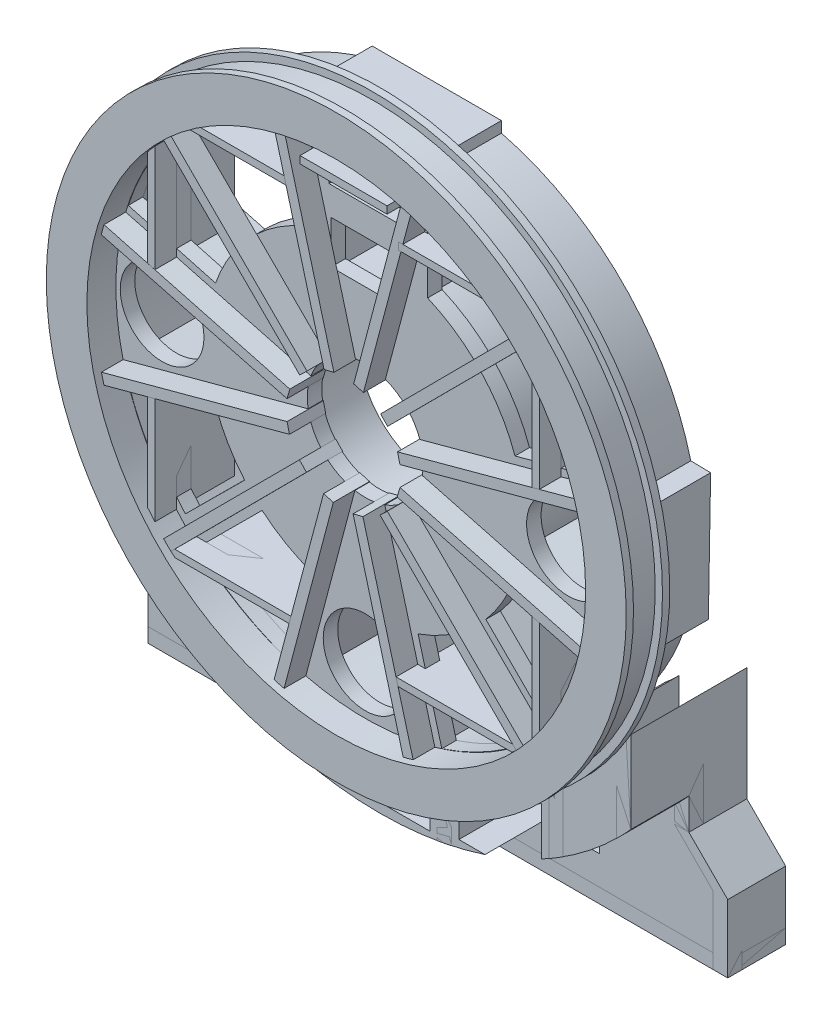
from build123d import *
from build123d.topology import SkipClean

# Parameters (mm, degrees)
SKETCH1_R                   = 200
BOSS_EXTRUDE1_DEPTH         = 5
SKETCH2_R                   = 195
BOSS_EXTRUDE2_DEPTH         = 10
SKETCH4_R                   = 180
SKETCH4_R_2                 = 172
BOSS_EXTRUDE3_DEPTH         = 40
CUT_EXTRUDE1_DEPTH          = 286.657137142
CUT_EXTRUDE1_DEPTH_BACK     = 286.657137142
SKETCH6_R                   = 40
SKETCH7_R                   = 172
CUT_EXTRUDE2_DEPTH          = 20
BOSS_EXTRUDE12_START        = -25
BOSS_EXTRUDE12_DEPTH        = 65
CIRPATTERN7_COUNT           = 12
SKETCH5_R                   = 104.5
SKETCH5_R_2                 = 96.5
BOSS_EXTRUDE14_DEPTH        = 40
SKETCH16_R                  = 63
SKETCH16_R_2                = 55
BOSS_EXTRUDE15_DEPTH        = 40
CUT_EXTRUDE9_START          = -40
SKETCH18_R                  = 55
CUT_EXTRUDE9_DEPTH          = 40
CUT_EXTRUDE13_DEPTH         = 40
BOSS_EXTRUDE18_START        = -40
SKETCH25_W                  = 60.032294261
SKETCH25_H                  = 45.012979572
BOSS_EXTRUDE18_DEPTH        = 40
SKETCH27_W                  = 60.032294261
SKETCH27_H                  = 45.012979572
SKETCH27_H_2                = 26.987020428
CUT_EXTRUDE15_DEPTH         = 40
CUT_EXTRUDE16_START         = -35
CUT_EXTRUDE16_DEPTH         = 35
BOSS_EXTRUDE19_START        = -44
SKETCH31_W                  = 5.866847787
SKETCH31_H                  = 9.437366397
SKETCH31_W_2                = 76.032294261
SKETCH31_W_3                = 7.195155409
BOSS_EXTRUDE19_DEPTH        = 44
BOSS_EXTRUDE20_DEPTH        = 80
BOSS_EXTRUDE21_DEPTH        = 80
BOSS_EXTRUDE21_2_DEPTH      = 80
BOSS_EXTRUDE26_DEPTH        = 50
CUT_EXTRUDE17_DEPTH         = 40
SKETCH41_W                  = 400
SKETCH41_H                  = 137.842811608
CUT_EXTRUDE18_DEPTH         = 452.7492864
BOSS_EXTRUDE29_DEPTH        = 40
BOSS_EXTRUDE29_DEPTH_BACK   = 10
SKETCH42_W                  = 400
SKETCH42_H                  = 10
BOSS_EXTRUDE31_DEPTH        = 40
CUT_EXTRUDE19_DEPTH         = 332.517722
CUT_EXTRUDE20_DEPTH         = 10
SKETCH50_W                  = 47.28
SKETCH50_H                  = 29.69
SKETCH50_W_2                = 50.032294261
SKETCH50_H_2                = 16.73
SKETCH50_H_3                = 10.87
SKETCH50_R                  = 28.87
SKETCH50_R_2                = 28.98
CUT_EXTRUDE21_DEPTH         = 10.1
BOSS_EXTRUDE32_DEPTH        = 30
BOSS_EXTRUDE32_DEPTH_BACK   = 25
BOSS_EXTRUDE32_2_DEPTH      = 30
BOSS_EXTRUDE32_2_DEPTH_BACK = 25
BOSS_EXTRUDE32_3_DEPTH      = 30
BOSS_EXTRUDE32_3_DEPTH_BACK = 25
BOSS_EXTRUDE32_4_DEPTH      = 30
BOSS_EXTRUDE32_4_DEPTH_BACK = 25
BOSS_EXTRUDE32_5_DEPTH      = 30
BOSS_EXTRUDE32_5_DEPTH_BACK = 25
BOSS_EXTRUDE32_6_DEPTH      = 30
BOSS_EXTRUDE32_6_DEPTH_BACK = 25
BOSS_EXTRUDE32_7_DEPTH      = 30
BOSS_EXTRUDE32_7_DEPTH_BACK = 25
BOSS_EXTRUDE32_8_DEPTH      = 30
BOSS_EXTRUDE32_8_DEPTH_BACK = 25
BOSS_EXTRUDE32_9_DEPTH      = 30
BOSS_EXTRUDE32_9_DEPTH_BACK = 25


with BuildPart() as part:
    # Sketch1 → Boss-Extrude1 (new body)
    with BuildSketch(Plane.XY):
        Circle(SKETCH1_R)
    boss_extrude1 = extrude(amount=BOSS_EXTRUDE1_DEPTH)

    # Sketch2 → Boss-Extrude2 (add)
    with BuildSketch(Plane.XY.offset(5)):
        Circle(SKETCH2_R)
    boss_extrude2 = extrude(amount=BOSS_EXTRUDE2_DEPTH)

    # Mirror2: Boss-Extrude2 across plane
    add(boss_extrude2.mirror(Plane.XY.offset(15)))

    # Mirror3: Boss-Extrude1 across plane
    add(boss_extrude1.mirror(Plane.XY.offset(15)))

    # Sketch4 → Boss-Extrude3 (add)
    with BuildSketch(Plane.XY):
        Circle(SKETCH4_R)
        Circle(SKETCH4_R_2, mode=Mode.SUBTRACT)
    extrude(amount=-BOSS_EXTRUDE3_DEPTH)

    # Sketch6 → Cut-Extrude1 (cut, two sides: drawn at the far end of the back side and taken through both)
    with BuildSketch(Plane(origin=(0, 0, 0), x_dir=(-1, 0, 0), z_dir=(0, 0, -1)).offset(-CUT_EXTRUDE1_DEPTH_BACK)):
        Circle(SKETCH6_R)
    extrude(amount=CUT_EXTRUDE1_DEPTH + CUT_EXTRUDE1_DEPTH_BACK, mode=Mode.SUBTRACT)

    # Sketch7 → Cut-Extrude2 (cut)
    with BuildSketch(Plane.XY.offset(30)):
        Circle(SKETCH7_R)
    extrude(amount=-CUT_EXTRUDE2_DEPTH, mode=Mode.SUBTRACT)

    # Sketch11 → Boss-Extrude12 (add)
    with BuildSketch(Plane(origin=(0, 0, 0), x_dir=(-1, 0, 0), z_dir=(0, 0, -1)).offset(BOSS_EXTRUDE12_START)):
        Polygon((7.035778174, -38.94988518), (13.739038842, -37.032866306), (48.739799741, -168.484156352), (41.858359492, -170.324504337), align=None)
    boss_extrude12 = extrude(amount=BOSS_EXTRUDE12_DEPTH)

    # CirPattern7: Boss-Extrude12 ×12 about axis
    cirpattern7_axis = Axis((0, 0, 0), (0, 0, 1))
    for i in range(1, CIRPATTERN7_COUNT):
        add(boss_extrude12.rotate(cirpattern7_axis, i * 360 / CIRPATTERN7_COUNT))

    # Sketch5 → Boss-Extrude14 (add)
    with BuildSketch(Plane(origin=(0, 0, 0), x_dir=(-1, 0, 0), z_dir=(0, 0, -1))):
        Circle(SKETCH5_R)
        Circle(SKETCH5_R_2, mode=Mode.SUBTRACT)
    extrude(amount=BOSS_EXTRUDE14_DEPTH)

    # Sketch16 → Boss-Extrude15 (add)
    with BuildSketch(Plane(origin=(0, 0, 0), x_dir=(-1, 0, 0), z_dir=(0, 0, -1))):
        Circle(SKETCH16_R)
        Circle(SKETCH16_R_2, mode=Mode.SUBTRACT)
    extrude(amount=BOSS_EXTRUDE15_DEPTH)

    # Sketch18 → Cut-Extrude9 (cut)
    with BuildSketch(Plane(origin=(0, 0, -40), x_dir=(-1, 0, 0), z_dir=(0, 0, -1)).offset(CUT_EXTRUDE9_START)):
        Circle(SKETCH18_R)
    extrude(amount=CUT_EXTRUDE9_DEPTH, mode=Mode.SUBTRACT)

    # Sketch20 → Cut-Extrude13 (cut)
    with SkipClean():  # the faces are left unmerged after this step: merging them gives an invalid solid
        with BuildSketch(Plane(origin=(0, 0, 0), x_dir=(-1, 0, 0), z_dir=(0, 0, -1))):
            with BuildLine():
                Line((-76.383232436, 71.315158295), (-124.056442132, 119.138571275))
                ThreePointArc((-124.056442132, 119.138571275), (0.082293709, 171.999980313), (124.170389449, 119.019806688))
                Line((124.170389449, 119.019806688), (76.298786502, 71.405498236))
                ThreePointArc((76.298786502, 71.405498236), (-0.061831263, 104.499981708), (-76.383232436, 71.315158295))
            make_face()
            with BuildLine():
                Line((-70.731344821, 65.645463361), (-47.053181493, 41.892697591))
                ThreePointArc((-47.053181493, 41.892697591), (-0.150655715, 62.999819864), (46.85228282, 42.117260055))
                Line((46.85228282, 42.117260055), (70.623866336, 65.761078943))
                ThreePointArc((70.623866336, 65.761078943), (-0.078928112, 96.499967722), (-70.731344821, 65.645463361))
            make_face()
        extrude(amount=CUT_EXTRUDE13_DEPTH, mode=Mode.SUBTRACT)

    # Sketch25 → Boss-Extrude18 (add)
    with SkipClean():  # the faces are left unmerged after this step: merging them gives an invalid solid
        with BuildSketch(Plane(origin=(0, 0, -40), x_dir=(-1, 0, 0), z_dir=(0, 0, -1)).offset(BOSS_EXTRUDE18_START)):
            with BuildLine():
                Line((38, 39.761790704), (38, 175.943172644))
                ThreePointArc((38, 175.943172644), (34.008709182, 176.758048472), (30, 177.482393493))
                Line((30, 177.482393493), (30, 130))
                Line((30, 130), (-30.032294261, 130))
                Line((-30.032294261, 130), (-30.032294261, 177.476931744))
                ThreePointArc((-30.032294261, 177.476931744), (-34.041012328, 176.751830202), (-38.032294261, 175.936194665))
                Line((-38.032294261, 175.936194665), (-38.032294261, 39.730902246))
                ThreePointArc((-38.032294261, 39.730902246), (-34.179881599, 43.089856044), (-30.032294261, 46.07668935))
                Line((-30.032294261, 46.07668935), (-30.032294261, 66.987020428))
                Line((-30.032294261, 66.987020428), (30, 66.987020428))
                Line((30, 66.987020428), (30, 46.097722286))
                ThreePointArc((30, 46.097722286), (34.147269397, 43.115704711), (38, 39.761790704))
            make_face()
            with Locations((-0.01614713, 99.493510214)):
                Rectangle(SKETCH25_W, SKETCH25_H, mode=Mode.SUBTRACT)
        extrude(amount=BOSS_EXTRUDE18_DEPTH)

    # Sketch27 → Cut-Extrude15 (cut)
    with SkipClean():  # the faces are left unmerged after this step: merging them gives an invalid solid
        with BuildSketch(Plane(origin=(0, 0, 0), x_dir=(-1, 0, 0), z_dir=(0, 0, -1))):
            with Locations((-0.01614713, 99.493510214)):
                Rectangle(SKETCH27_W, SKETCH27_H)
            with Locations((-0.01614713, 53.493510214)):
                Rectangle(SKETCH27_W, SKETCH27_H_2)
        extrude(amount=CUT_EXTRUDE15_DEPTH, mode=Mode.SUBTRACT)

    # Sketch30 → Cut-Extrude16 (cut)
    with SkipClean():  # the faces are left unmerged after this step: merging them gives an invalid solid
        with BuildSketch(Plane(origin=(0, 0, -50), x_dir=(-1, 0, 0), z_dir=(0, 0, -1)).offset(CUT_EXTRUDE16_START)):
            with BuildLine():
                Line((-38.032294261, 130), (38, 130))
                Line((38, 130), (38, 167.749813711))
                ThreePointArc((38, 167.749813711), (-0.016556603, 171.999999203), (-38.032294261, 167.742494894))
                Line((-38.032294261, 167.742494894), (-38.032294261, 130))
            make_face()
        extrude(amount=CUT_EXTRUDE16_DEPTH, mode=Mode.SUBTRACT)

    # Sketch31 → Boss-Extrude19 (add)
    with SkipClean():  # the faces are left unmerged after this step: merging them gives an invalid solid
        with BuildSketch(Plane(origin=(0, 0, -40), x_dir=(-1, 0, 0), z_dir=(0, 0, -1)).offset(BOSS_EXTRUDE19_START)):
            with BuildLine():
                ThreePointArc((-43.899142048, 166.303533719), (-40.972035783, 167.048772171), (-38.032294261, 167.742494894))
                Line((-38.032294261, 167.742494894), (-38.032294261, 172.64311533))
                Line((-38.032294261, 172.64311533), (-43.899142048, 172.64311533))
                Line((-43.899142048, 172.64311533), (-43.899142048, 166.303533719))
            make_face()
            with Locations((-40.965718155, 177.361798529)):
                Rectangle(SKETCH31_W, SKETCH31_H)
            with Locations((-0.016147131, 177.361798529)):
                Rectangle(SKETCH31_W_2, SKETCH31_H)
            with BuildLine():
                Line((-38.032294261, 172.64311533), (-38.032294261, 167.742494894))
                ThreePointArc((-38.032294261, 167.742494894), (-0.016556603, 171.999999203), (38, 167.749813711))
                Line((38, 167.749813711), (38, 172.64311533))
                Line((38, 172.64311533), (-38.032294261, 172.64311533))
            make_face()
            with BuildLine():
                Line((38, 172.64311533), (38, 167.749813711))
                ThreePointArc((38, 167.749813711), (41.607245787, 166.891692717), (45.195155409, 165.956012026))
                Line((45.195155409, 165.956012026), (45.195155409, 172.64311533))
                Line((45.195155409, 172.64311533), (38, 172.64311533))
            make_face()
            with Locations((41.597577704, 177.361798529)):
                Rectangle(SKETCH31_W_3, SKETCH31_H)
        extrude(amount=BOSS_EXTRUDE19_DEPTH)

    # Sketch32 → Boss-Extrude20 (add)
    with SkipClean():  # the faces are left unmerged after this step: merging them gives an invalid solid
        with BuildSketch(Plane.XY):
            with BuildLine():
                Line((125.869176934, -389.842811608), (126.470649272, -154.528527603))
                ThreePointArc((126.470649272, -154.528527603), (121.628078628, -158.368246375), (116.66900432, -162.056269245))
                Line((116.66900432, -162.056269245), (116.086773179, -389.842811608))
                Line((116.086773179, -389.842811608), (125.869176934, -389.842811608))
            make_face()
            with BuildLine():
                Line((126.470649272, -154.528527603), (126.538416981, -128.015737423))
                ThreePointArc((126.538416981, -128.015737423), (121.718930634, -132.606568183), (116.733008017, -137.016075113))
                Line((116.733008017, -137.016075113), (116.66900432, -162.056269245))
                ThreePointArc((116.66900432, -162.056269245), (121.628078628, -158.368246375), (126.470649272, -154.528527603))
            make_face()
            with BuildLine():
                Line((49.586808273, -193.429675634), (49.586808273, -173.035107551))
                ThreePointArc((49.586808273, -173.035107551), (44.605146714, -174.385724435), (39.586808273, -175.592951484))
                Line((39.586808273, -175.592951484), (39.586808273, -195.721167944))
                ThreePointArc((39.586808273, -195.721167944), (44.601526949, -194.639653628), (49.586808273, -193.429675634))
            make_face()
            with BuildLine():
                Line((49.586808273, -389.842811608), (49.586808273, -193.429675634))
                ThreePointArc((49.586808273, -193.429675634), (44.601526949, -194.639653628), (39.586808273, -195.721167944))
                Line((39.586808273, -195.721167944), (39.586808273, -389.842811608))
                Line((39.586808273, -389.842811608), (49.586808273, -389.842811608))
            make_face()
            with BuildLine():
                ThreePointArc((-39.427863087, -175.628709534), (-44.446127643, -174.426321802), (-49.427863087, -173.080577624))
                Line((-49.427863087, -173.080577624), (-49.427863087, -193.470352564))
                ThreePointArc((-49.427863087, -193.470352564), (-44.442523811, -194.676020731), (-39.427863087, -195.753249227))
                Line((-39.427863087, -195.753249227), (-39.427863087, -175.628709534))
            make_face()
            with BuildLine():
                ThreePointArc((-39.427863087, -195.753249227), (-44.442523811, -194.676020731), (-49.427863087, -193.470352564))
                Line((-49.427863087, -193.470352564), (-49.427863087, -389.842811608))
                Line((-49.427863087, -389.842811608), (-39.427863087, -389.842811608))
                Line((-39.427863087, -389.842811608), (-39.427863087, -195.753249227))
            make_face()
            with BuildLine():
                ThreePointArc((-116.53812441, -137.181870373), (-121.624499416, -132.693184233), (-126.53812441, -128.016026617))
                Line((-126.53812441, -128.016026617), (-126.53812441, -154.473279376))
                ThreePointArc((-126.53812441, -154.473279376), (-121.598726479, -158.390784736), (-116.53812441, -162.150413288))
                Line((-116.53812441, -162.150413288), (-116.53812441, -137.181870373))
            make_face()
            with BuildLine():
                ThreePointArc((-116.53812441, -162.150413288), (-121.598726479, -158.390784736), (-126.53812441, -154.473279376))
                Line((-126.53812441, -154.473279376), (-126.53812441, -389.842811608))
                Line((-126.53812441, -389.842811608), (-116.53812441, -389.842811608))
                Line((-116.53812441, -389.842811608), (-116.53812441, -162.150413288))
            make_face()
        extrude(amount=-BOSS_EXTRUDE20_DEPTH)


with BuildPart() as body_2:
    # Sketch33 → Boss-Extrude21 (new body)
    with BuildSketch(Plane(origin=(0, 0, 0), x_dir=(-1, 0, 0), z_dir=(0, 0, -1))):
        with BuildLine():
            ThreePointArc((-163.205080757, -115.603207633), (-168.385908599, -107.91749527), (-173.205080757, -100))
            Line((-173.205080757, -100), (-173.205080757, -178.365564659))
            Line((-173.205080757, -178.365564659), (-200, -205.160483902))
            Line((-200, -205.160483902), (-200, -389.842811608))
            Line((-200, -389.842811608), (-190, -389.842811608))
            Line((-190, -389.842811608), (-190, -205.160483902))
            Line((-190, -205.160483902), (-163.205080757, -178.365564659))
            Line((-163.205080757, -178.365564659), (-163.205080757, -115.603207633))
        make_face()
    extrude(amount=BOSS_EXTRUDE21_DEPTH)


with BuildPart() as body_3:
    # Sketch33 → Boss-Extrude21 2 (new body)
    with BuildSketch(Plane(origin=(0, 0, 0), x_dir=(-1, 0, 0), z_dir=(0, 0, -1))):
        with BuildLine():
            ThreePointArc((173.205080757, -100), (168.385908599, -107.91749527), (163.205080757, -115.603207633))
            Line((163.205080757, -115.603207633), (163.205080757, -178.648465684))
            Line((163.205080757, -178.648465684), (190, -205.443384928))
            Line((190, -205.443384928), (190, -389.842811608))
            Line((190, -389.842811608), (200, -389.842811608))
            Line((200, -389.842811608), (200, -205.443384928))
            Line((200, -205.443384928), (173.205080757, -178.648465684))
            Line((173.205080757, -178.648465684), (173.205080757, -100))
        make_face()
    extrude(amount=BOSS_EXTRUDE21_2_DEPTH)


with BuildPart() as body_4:
    # Sketch34 → Boss-Extrude26 (new body)
    with BuildSketch(Plane(origin=(0, 0, 0), x_dir=(-1, 0, 0), z_dir=(0, 0, -1))):
        with BuildLine():
            Line((-200, -205.160483902), (-200, -389.842811608))
            Line((-200, -389.842811608), (200, -389.842811608))
            Line((200, -389.842811608), (200, -205.443384928))
            Line((200, -205.443384928), (173.205080757, -178.648465684))
            Line((173.205080757, -178.648465684), (173.205080757, -100))
            ThreePointArc((173.205080757, -100), (0, -200), (-173.205080757, -100))
            Line((-173.205080757, -100), (-173.205080757, -178.365564659))
            Line((-173.205080757, -178.365564659), (-200, -205.160483902))
        make_face()
    extrude(amount=BOSS_EXTRUDE26_DEPTH)


with BuildPart() as cut_extrude17_tool:
    # Sketch39 → Cut-Extrude17 (new body)
    with SkipClean():  # the faces are left unmerged after this step: merging them gives an invalid solid
        with BuildSketch(Plane.XY.offset(10)):
            with BuildLine():
                Line((-233.56, 0), (-438.152276911, 0))
                ThreePointArc((-438.152276911, 0), (0, -438.152276911), (438.152276911, 0))
                Line((438.152276911, 0), (233.56, 0))
                ThreePointArc((233.56, 0), (0, -233.56), (-233.56, 0))
            make_face()
        extrude(amount=-CUT_EXTRUDE17_DEPTH)


with BuildPart() as part_1:
    with SkipClean():  # the faces are left unmerged after this step: merging them gives an invalid solid
        add(part.part)

        # Cut-Extrude17: cut by cut_extrude17_tool
        add(cut_extrude17_tool.part, mode=Mode.SUBTRACT)


with BuildPart() as body_2_1:
    with SkipClean():  # the faces are left unmerged after this step: merging them gives an invalid solid
        add(body_2.part)

        # Cut-Extrude17: cut by cut_extrude17_tool
        add(cut_extrude17_tool.part, mode=Mode.SUBTRACT)


with BuildPart() as body_3_1:
    with SkipClean():  # the faces are left unmerged after this step: merging them gives an invalid solid
        add(body_3.part)

        # Cut-Extrude17: cut by cut_extrude17_tool
        add(cut_extrude17_tool.part, mode=Mode.SUBTRACT)


with BuildPart() as body_4_1:
    with SkipClean():  # the faces are left unmerged after this step: merging them gives an invalid solid
        add(body_4.part)

        # Cut-Extrude17: cut by cut_extrude17_tool
        add(cut_extrude17_tool.part, mode=Mode.SUBTRACT)


with BuildPart() as cut_extrude18_tool:
    # Sketch41 → Cut-Extrude18 (new, through all)
    with SkipClean():  # the faces are left unmerged after this step: merging them gives an invalid solid
        with BuildSketch(Plane.XY.offset(30)):
            with Locations((0, -320.921405804)):
                Rectangle(SKETCH41_W, SKETCH41_H)
        extrude(amount=-CUT_EXTRUDE18_DEPTH)


with BuildPart() as part_2:
    with SkipClean():  # the faces are left unmerged after this step: merging them gives an invalid solid
        add(part_1.part)

        # Cut-Extrude18: cut by cut_extrude18_tool
        add(cut_extrude18_tool.part, mode=Mode.SUBTRACT)

    # Sketch43 → Boss-Extrude31 (add)
    with SkipClean():  # the faces are left unmerged after this step: merging them gives an invalid solid
        with BuildSketch(Plane(origin=(0, 0, 0), x_dir=(-1, 0, 0), z_dir=(0, 0, -1))):
            with BuildLine():
                Line((187.415787156, -44.121318283), (187.415787156, 44.323576393))
                Line((187.415787156, 44.323576393), (170.006798903, 44.323576393))
                ThreePointArc((170.006798903, 44.323576393), (175.624573521, 0), (168.59264001, -44.121318283))
                Line((168.59264001, -44.121318283), (187.415787156, -44.121318283))
            make_face()
            with BuildLine():
                Line((-188.196191284, 43.90881334), (-186.652615034, -44.53118666))
                Line((-186.652615034, -44.53118666), (-169.246278254, -44.227357921))
                ThreePointArc((-169.246278254, -44.227357921), (-175.637997636, -0.00430477), (-169.375910437, 44.237290709))
                Line((-169.375910437, 44.237290709), (-188.196191284, 43.90881334))
            make_face()
        extrude(amount=BOSS_EXTRUDE31_DEPTH)


with BuildPart() as body_2_2:
    with SkipClean():  # the faces are left unmerged after this step: merging them gives an invalid solid
        add(body_2_1.part)

        # Cut-Extrude18: cut by cut_extrude18_tool
        add(cut_extrude18_tool.part, mode=Mode.SUBTRACT)


with BuildPart() as body_3_2:
    with SkipClean():  # the faces are left unmerged after this step: merging them gives an invalid solid
        add(body_3_1.part)

        # Cut-Extrude18: cut by cut_extrude18_tool
        add(cut_extrude18_tool.part, mode=Mode.SUBTRACT)


with BuildPart() as body_4_2:
    with SkipClean():  # the faces are left unmerged after this step: merging them gives an invalid solid
        add(body_4_1.part)

        # Cut-Extrude18: cut by cut_extrude18_tool
        add(cut_extrude18_tool.part, mode=Mode.SUBTRACT)

    # Sketch45 → Cut-Extrude19 (cut, through all)
    with BuildSketch(Plane(origin=(0, 0, -50), x_dir=(-1, 0, 0), z_dir=(0, 0, -1))):
        with BuildLine():
            Line((34.427863087, -227), (34.427863087, -202.08840205))
            ThreePointArc((34.427863087, -202.08840205), (-0.080623006, -204.999984146), (-34.586808273, -202.061259754))
            Line((-34.586808273, -202.061259754), (-34.586808273, -227))
            Line((-34.586808273, -227), (34.427863087, -227))
        make_face()
        with BuildLine():
            Line((54.427863087, -197.642626272), (54.427863087, -222))
            Line((54.427863087, -222), (111.53812441, -222))
            Line((111.53812441, -222), (111.53812441, -172.000717449))
            ThreePointArc((111.53812441, -172.000717449), (83.967577811, -187.0145606), (54.427863087, -197.642626272))
        make_face()
        with BuildLine():
            ThreePointArc((-54.586808273, -197.598786339), (-84.030627785, -186.98623905), (-111.515769511, -172.015211974))
            Line((-111.515769511, -172.015211974), (-111.515769511, -222))
            Line((-111.515769511, -222), (-54.586808273, -222))
            Line((-54.586808273, -222), (-54.586808273, -197.598786339))
        make_face()
    extrude(amount=-CUT_EXTRUDE19_DEPTH, mode=Mode.SUBTRACT)


with BuildPart() as body_5:
    # Sketch42 → Boss-Extrude29 (new, two sides: drawn at the far end of the back side and taken through both)
    with BuildSketch(Plane(origin=(0, 0, -40), x_dir=(-1, 0, 0), z_dir=(0, 0, -1)).offset(-BOSS_EXTRUDE29_DEPTH_BACK)):
        with Locations((0, -247)):
            Rectangle(SKETCH42_W, SKETCH42_H)
    extrude(amount=BOSS_EXTRUDE29_DEPTH + BOSS_EXTRUDE29_DEPTH_BACK)


with BuildPart() as cut_extrude20_tool:
    # Sketch48 → Cut-Extrude20 (new body)
    with SkipClean():  # the faces are left unmerged after this step: merging them gives an invalid solid
        with BuildSketch(Plane.XY.offset(-30)):
            with BuildLine():
                Line((-200, -252), (200, -252))
                Line((200, -252), (200, -155.878801719))
                Line((200, -155.878801719), (173.931230016, -155.878801719))
                ThreePointArc((173.931230016, -155.878801719), (0, -233.56), (-173.931230016, -155.878801719))
                Line((-173.931230016, -155.878801719), (-200, -155.878801719))
                Line((-200, -155.878801719), (-200, -252))
            make_face()
        extrude(amount=-CUT_EXTRUDE20_DEPTH)


with BuildPart() as part_3:
    with SkipClean():  # the faces are left unmerged after this step: merging them gives an invalid solid
        add(part_2.part)

        # Cut-Extrude20: cut by cut_extrude20_tool
        add(cut_extrude20_tool.part, mode=Mode.SUBTRACT)

    # Sketch50 → Cut-Extrude21 (cut)
    with SkipClean():  # the faces are left unmerged after this step: merging them gives an invalid solid
        with BuildSketch(Plane(origin=(0, 0, 0), x_dir=(-1, 0, 0), z_dir=(0, 0, -1))):
            with BuildLine():
                Line((-43.032294261, 134.173422282), (-99.43081205, 134.173446013))
                ThreePointArc((-99.43081205, 134.173446013), (-115.692391285, 120.433677178), (-130.073869782, 104.736757636))
                Line((-130.073869782, 104.736757636), (-130.073869782, 43.702414799))
                Line((-130.073869782, 43.702414799), (-103.258836778, 36.439849441))
                ThreePointArc((-103.258836778, 36.439849441), (-79.88925777, 74.88629042), (-43.032294261, 100.689977906))
                Line((-43.032294261, 100.689977906), (-43.032294261, 134.173422282))
            make_face()
            with BuildLine():
                ThreePointArc((-100.83456256, 139.173446604), (-73.076431786, 155.246918058), (-43.032294261, 166.481690376))
                Line((-43.032294261, 166.481690376), (-43.032294261, 139.173422282))
                Line((-43.032294261, 139.173422282), (-100.83456256, 139.173446604))
            make_face()
            with BuildLine():
                Line((43.032294261, 139.173422282), (100.83456256, 139.173446604))
                ThreePointArc((100.83456256, 139.173446604), (73.076431786, 155.246918058), (43.032294261, 166.481690376))
                Line((43.032294261, 166.481690376), (43.032294261, 139.173422282))
            make_face()
            with Locations((0, 100.689977906)):
                Rectangle(SKETCH50_W, SKETCH50_H)
            with Locations((-0.016147131, 143.365)):
                Rectangle(SKETCH50_W_2, SKETCH50_H_2)
            with Locations((-0.016147131, 162.165)):
                Rectangle(SKETCH50_W_2, SKETCH50_H_3)
            with BuildLine():
                Line((43.032294261, 100.689977906), (43.032294261, 134.173422282))
                Line((43.032294261, 134.173422282), (99.43081205, 134.173446013))
                ThreePointArc((99.43081205, 134.173446013), (115.692391285, 120.433677178), (130.073869782, 104.736757636))
                Line((130.073869782, 104.736757636), (130.073869782, 43.702414799))
                Line((130.073869782, 43.702414799), (103.258836778, 36.439849441))
                ThreePointArc((103.258836778, 36.439849441), (79.88925777, 74.88629042), (43.032294261, 100.689977906))
            make_face()
            with BuildLine():
                ThreePointArc((135.073869782, 106.484974068), (151.615025455, 80.855798311), (163.451334031, 52.742344588))
                Line((163.451334031, 52.742344588), (135.073869782, 45.05661141))
                Line((135.073869782, 45.05661141), (135.073869782, 106.484974068))
            make_face()
            with Locations((140.118556434, 0)):
                Circle(SKETCH50_R)
            with Locations((-140.118556434, 0)):
                Circle(SKETCH50_R)
            with BuildLine():
                Line((-135.073869782, 45.05661141), (-135.073869782, 106.484974068))
                ThreePointArc((-135.073869782, 106.484974068), (-151.615025455, 80.855798311), (-163.451334031, 52.742344588))
                Line((-163.451334031, 52.742344588), (-135.073869782, 45.05661141))
            make_face()
            with BuildLine():
                Line((-163.542941381, -52.598338176), (-135.078802669, -45.019359583))
                Line((-135.078802669, -45.019359583), (-135.078802669, -106.063437591))
                ThreePointArc((-135.078802669, -106.063437591), (-151.643657921, -80.572833415), (-163.542941381, -52.598338176))
            make_face()
            with BuildLine():
                Line((-130.078802669, -43.688039027), (-130.078802669, -104.730631127))
                ThreePointArc((-130.078802669, -104.730631127), (-127.103994027, -108.321626199), (-124.030083865, -111.828164147))
                Line((-124.030083865, -111.828164147), (-83.187253715, -71.204851095))
                ThreePointArc((-83.187253715, -71.204851095), (-94.803840961, -54.794906142), (-103.224273944, -36.537641807))
                Line((-103.224273944, -36.537641807), (-130.078802669, -43.688039027))
            make_face()
            with BuildLine():
                ThreePointArc((-71.126022619, -83.254662971), (-54.705081578, -94.855701197), (-36.439849441, -103.258836778))
                Line((-36.439849441, -103.258836778), (-41.395560469, -121.556442132))
                Line((-41.395560469, -121.556442132), (-109.548478635, -121.556442132))
                Line((-109.548478635, -121.556442132), (-71.126022619, -83.254662971))
            make_face()
            with BuildLine():
                Line((-116.20461587, -126.556442132), (-42.74975708, -126.556442132))
                Line((-42.74975708, -126.556442132), (-52.796747929, -163.652203466))
                ThreePointArc((-52.796747929, -163.652203466), (-86.448515387, -148.433758943), (-116.20461587, -126.556442132))
            make_face()
            with BuildLine():
                ThreePointArc((116.20461587, -126.556442132), (86.448515387, -148.433758943), (52.796747929, -163.652203466))
                Line((52.796747929, -163.652203466), (42.74975708, -126.556442132))
                Line((42.74975708, -126.556442132), (116.20461587, -126.556442132))
            make_face()
            with BuildLine():
                Line((109.548478635, -121.556442132), (71.126022619, -83.254662971))
                ThreePointArc((71.126022619, -83.254662971), (54.705081578, -94.855701197), (36.439849441, -103.258836778))
                Line((36.439849441, -103.258836778), (41.395560469, -121.556442132))
                Line((41.395560469, -121.556442132), (109.548478635, -121.556442132))
            make_face()
            with BuildLine():
                Line((130.078802669, -43.688039027), (103.224273944, -36.537641807))
                ThreePointArc((103.224273944, -36.537641807), (94.803840961, -54.794906142), (83.187253715, -71.204851095))
                Line((83.187253715, -71.204851095), (124.030083865, -111.828164147))
                ThreePointArc((124.030083865, -111.828164147), (127.103994027, -108.321626199), (130.078802669, -104.730631127))
                Line((130.078802669, -104.730631127), (130.078802669, -43.688039027))
            make_face()
            with BuildLine():
                ThreePointArc((163.542941381, -52.598338176), (151.643657921, -80.572833415), (135.078802669, -106.063437591))
                Line((135.078802669, -106.063437591), (135.078802669, -45.019359583))
                Line((135.078802669, -45.019359583), (163.542941381, -52.598338176))
            make_face()
            with Locations((0, -138.388993284)):
                Circle(SKETCH50_R_2)
        extrude(amount=-CUT_EXTRUDE21_DEPTH, mode=Mode.SUBTRACT)


with BuildPart() as body_2_3:
    with SkipClean():  # the faces are left unmerged after this step: merging them gives an invalid solid
        add(body_2_2.part)

        # Cut-Extrude20: cut by cut_extrude20_tool
        add(cut_extrude20_tool.part, mode=Mode.SUBTRACT)


with BuildPart() as body_3_3:
    with SkipClean():  # the faces are left unmerged after this step: merging them gives an invalid solid
        add(body_3_2.part)

        # Cut-Extrude20: cut by cut_extrude20_tool
        add(cut_extrude20_tool.part, mode=Mode.SUBTRACT)


with BuildPart() as body_4_3:
    with SkipClean():  # the faces are left unmerged after this step: merging them gives an invalid solid
        add(body_4_2.part)

        # Cut-Extrude20: cut by cut_extrude20_tool
        add(cut_extrude20_tool.part, mode=Mode.SUBTRACT)


with BuildPart() as body_5_1:
    with SkipClean():  # the faces are left unmerged after this step: merging them gives an invalid solid
        add(body_5.part)

        # Cut-Extrude20: cut by cut_extrude20_tool
        add(cut_extrude20_tool.part, mode=Mode.SUBTRACT)


with BuildPart() as body_6:
    # Sketch51 → Boss-Extrude32 (new, two sides: drawn at the far end of the back side and taken through both)
    with BuildSketch(Plane(origin=(0, 0, 0), x_dir=(-1, 0, 0), z_dir=(0, 0, -1)).offset(-BOSS_EXTRUDE32_DEPTH_BACK)):
        Polygon((-135.078802669, -45.019359583), (-135.078802669, -106.063437591), (-130.078802669, -112.052108983), (-130.078802669, -43.688039027), (-130.078802669, -38.513832381), (-135.078802669, -39.845152936), align=None)
    extrude(amount=BOSS_EXTRUDE32_DEPTH + BOSS_EXTRUDE32_DEPTH_BACK)


with BuildPart() as body_7:
    # Sketch51 → Boss-Extrude32 2 (new, two sides: drawn at the far end of the back side and taken through both)
    with BuildSketch(Plane(origin=(0, 0, 0), x_dir=(-1, 0, 0), z_dir=(0, 0, -1)).offset(-BOSS_EXTRUDE32_2_DEPTH_BACK)):
        Polygon((-109.548478635, -121.556442132), (-116.630694562, -121.556442132), (-119.138571275, -124.056442132), (-116.20461587, -126.556442132), (-37.569617269, -126.556442132), (-36.215420659, -121.556442132), align=None)
    extrude(amount=BOSS_EXTRUDE32_2_DEPTH + BOSS_EXTRUDE32_2_DEPTH_BACK)


with BuildPart() as body_8:
    # Sketch51 → Boss-Extrude32 3 (new, two sides: drawn at the far end of the back side and taken through both)
    with BuildSketch(Plane(origin=(0, 0, 0), x_dir=(-1, 0, 0), z_dir=(0, 0, -1)).offset(-BOSS_EXTRUDE32_3_DEPTH_BACK)):
        Polygon((-135.073869782, 106.484974068), (-135.073869782, 39.876471599), (-130.078802669, 38.523611008), (-130.078802669, 112.532240253), align=None)
    extrude(amount=BOSS_EXTRUDE32_3_DEPTH + BOSS_EXTRUDE32_3_DEPTH_BACK)


with BuildPart() as body_9:
    # Sketch51 → Boss-Extrude32 4 (new, two sides: drawn at the far end of the back side and taken through both)
    with BuildSketch(Plane(origin=(0, 0, 0), x_dir=(-1, 0, 0), z_dir=(0, 0, -1)).offset(-BOSS_EXTRUDE32_4_DEPTH_BACK)):
        Polygon((-99.43081205, 134.173446013), (-38.032294261, 134.173446013), (-38.032294261, 139.173446013), (-99.43081205, 139.173446013), (-100.83456256, 139.173446604), (-107.617314522, 134.173446013), align=None)
    extrude(amount=BOSS_EXTRUDE32_4_DEPTH + BOSS_EXTRUDE32_4_DEPTH_BACK)


with BuildPart() as body_10:
    # Sketch51 → Boss-Extrude32 5 (new, two sides: drawn at the far end of the back side and taken through both)
    with BuildSketch(Plane(origin=(0, 0, 0), x_dir=(-1, 0, 0), z_dir=(0, 0, -1)).offset(-BOSS_EXTRUDE32_5_DEPTH_BACK)):
        Polygon((37.569617269, -126.556442132), (36.215420659, -121.556442132), (109.548478635, -121.556442132), (116.630694562, -121.556442132), (119.138571275, -124.056442132), (116.20461587, -126.556442132), align=None)
    extrude(amount=BOSS_EXTRUDE32_5_DEPTH + BOSS_EXTRUDE32_5_DEPTH_BACK)


with BuildPart() as body_11:
    # Sketch51 → Boss-Extrude32 6 (new, two sides: drawn at the far end of the back side and taken through both)
    with BuildSketch(Plane(origin=(0, 0, 0), x_dir=(-1, 0, 0), z_dir=(0, 0, -1)).offset(-BOSS_EXTRUDE32_6_DEPTH_BACK)):
        Polygon((99.43081205, 134.173446013), (107.617314522, 134.173446013), (100.83456256, 139.173446604), (99.43081205, 139.173446013), (38.032294261, 139.173446013), (38.032294261, 134.173446013), align=None)
    extrude(amount=BOSS_EXTRUDE32_6_DEPTH + BOSS_EXTRUDE32_6_DEPTH_BACK)


with BuildPart() as body_12:
    # Sketch51 → Boss-Extrude32 7 (new, two sides: drawn at the far end of the back side and taken through both)
    with BuildSketch(Plane(origin=(0, 0, 0), x_dir=(-1, 0, 0), z_dir=(0, 0, -1)).offset(-BOSS_EXTRUDE32_7_DEPTH_BACK)):
        Polygon((130.078802669, 38.523611008), (130.078802669, 112.532240253), (135.073869782, 106.484974068), (135.073869782, 39.876471599), align=None)
    extrude(amount=BOSS_EXTRUDE32_7_DEPTH + BOSS_EXTRUDE32_7_DEPTH_BACK)


with BuildPart() as body_13:
    # Sketch51 → Boss-Extrude32 8 (new, two sides: drawn at the far end of the back side and taken through both)
    with BuildSketch(Plane(origin=(0, 0, 0), x_dir=(-1, 0, 0), z_dir=(0, 0, -1)).offset(-BOSS_EXTRUDE32_8_DEPTH_BACK)):
        Polygon((130.078802669, -43.688039027), (130.078802669, -112.052108983), (135.078802669, -106.063437591), (135.078802669, -45.019359583), (135.078802669, -39.845152936), (130.078802669, -38.513832381), align=None)
    extrude(amount=BOSS_EXTRUDE32_8_DEPTH + BOSS_EXTRUDE32_8_DEPTH_BACK)


with BuildPart() as body_14:
    # Sketch51 → Boss-Extrude32 9 (new, two sides: drawn at the far end of the back side and taken through both)
    with BuildSketch(Plane(origin=(0, 0, 0), x_dir=(-1, 0, 0), z_dir=(0, 0, -1)).offset(-BOSS_EXTRUDE32_9_DEPTH_BACK)):
        Polygon((-25.032294261, 151.73), (30, 151.73), (30, 156.73), (-30.032294261, 156.73), (-30.032294261, 151.73), align=None)
    extrude(amount=BOSS_EXTRUDE32_9_DEPTH + BOSS_EXTRUDE32_9_DEPTH_BACK)


solid = Compound([part_3.part, body_2_3.part, body_3_3.part, body_4_3.part, body_5_1.part, body_6.part, body_7.part, body_8.part, body_9.part, body_10.part, body_11.part, body_12.part, body_13.part, body_14.part])
